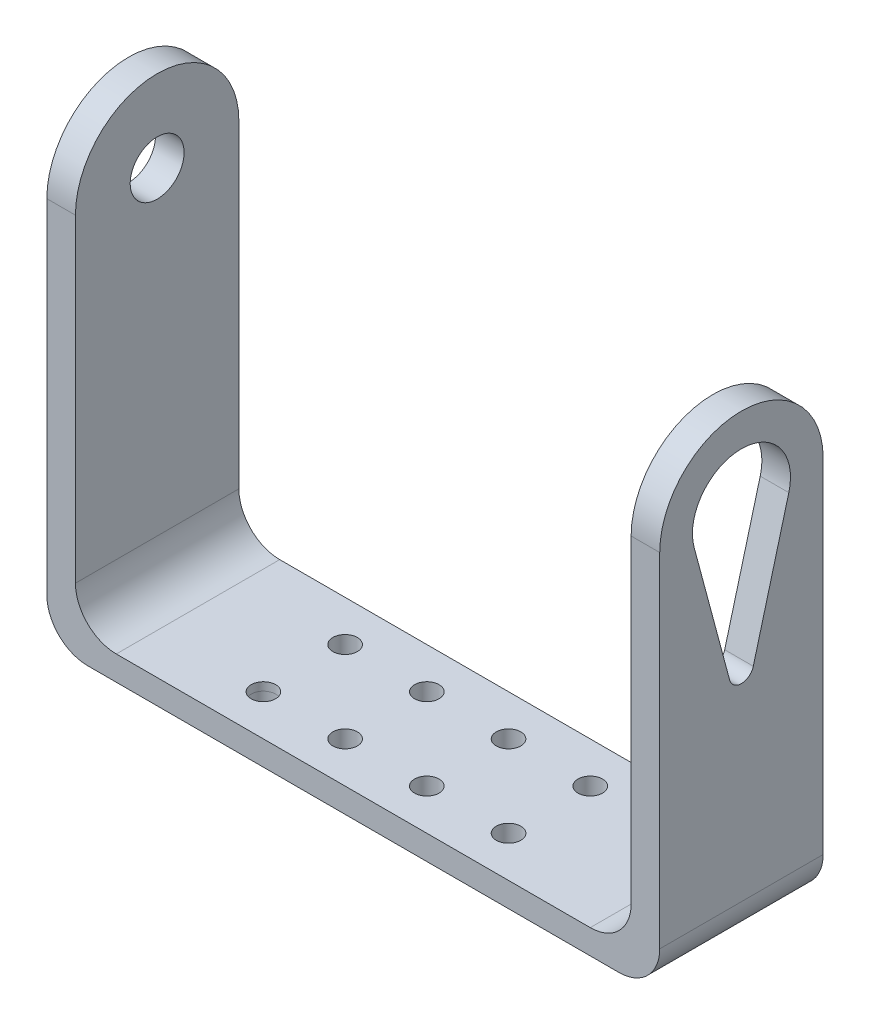
from build123d import *

# Parameters (mm, degrees)
SKETCH_2_R          = 1.5
EXTRUDE_1_DEPTH     = 2
SKETCH_3_W          = 2
SKETCH_3_H          = 20
SKETCH_3_W_2        = 3.5
EXTRUDE_2_DEPTH     = 55
SKETCH_9_R          = 6
CUT_EXTRUDE_1_DEPTH = 87
SKETCH_7_R          = 6
SKETCH_7_R_2        = 3.3
EXTRUDE_3_DEPTH     = 2
SKETCH_10_R         = 3.3
EXTRUDE_4_DEPTH     = 1.5
SKETCH_11_W         = 68
SKETCH_11_H         = 20
SKETCH_11_R         = 1.5
SKETCH_11_R_2       = 1.498871695
EXTRUDE_5_DEPTH     = 1
FILLET_6_R          = 5
FILLET_7_R          = 5
FILLET_8_R          = 5
CUT_EXTRUDE_2_DEPTH = 3.5


with BuildPart() as part:
    # 스케치2 → 보스-돌출1 (new body)
    with BuildSketch(Plane(origin=(0, 0, 0), x_dir=(1, 0, 0), z_dir=(0, 1, 0))):
        Polygon((35, -10), (-35, -10), (-35, 10), (35, 10), (38.5, 10), (38.5, -10), align=None)
        with Locations((-15, 5)):
            Circle(SKETCH_2_R, mode=Mode.SUBTRACT)
        with Locations((-5, 5)):
            Circle(SKETCH_2_R, mode=Mode.SUBTRACT)
        with Locations((-15, -5)):
            Circle(SKETCH_2_R, mode=Mode.SUBTRACT)
        with Locations((-5, -5)):
            Circle(SKETCH_2_R, mode=Mode.SUBTRACT)
        with Locations((15, -5)):
            Circle(SKETCH_2_R, mode=Mode.SUBTRACT)
        with Locations((5, -5)):
            Circle(SKETCH_2_R, mode=Mode.SUBTRACT)
        with Locations((5, 5)):
            Circle(SKETCH_2_R, mode=Mode.SUBTRACT)
        with Locations((15, 5)):
            Circle(SKETCH_2_R, mode=Mode.SUBTRACT)
    extrude(amount=EXTRUDE_1_DEPTH)

    # 스케치3 → 보스-돌출2 (add)
    with BuildSketch(Plane(origin=(0, 2, 0), x_dir=(1, 0, 0), z_dir=(0, 1, 0))):
        with Locations((-34, 0)):
            Rectangle(SKETCH_3_W, SKETCH_3_H)
        with Locations((36.75, 0)):
            Rectangle(SKETCH_3_W_2, SKETCH_3_H)
    extrude(amount=EXTRUDE_2_DEPTH)

    # 스케치9 → 컷-돌출1 (cut)
    with BuildSketch(Plane(origin=(38.5, 0, 0), x_dir=(0, 0, -1), z_dir=(1, 0, 0))):
        with BuildLine():
            Line((10, 57), (0, 57))
            ThreePointArc((0, 57), (7.071067812, 54.071067812), (10, 47))
            Line((10, 47), (10, 57))
        make_face()
        with BuildLine():
            Line((-10, 57), (-10, 47))
            ThreePointArc((-10, 47), (-7.071067812, 54.071067812), (0, 57))
            Line((0, 57), (-10, 57))
        make_face()
        with Locations((0, 47)):
            Circle(SKETCH_9_R)
    extrude(amount=-CUT_EXTRUDE_1_DEPTH, mode=Mode.SUBTRACT)

    # 스케치7 → 보스-돌출3 (add)
    with BuildSketch(Plane.ZY.offset(35)):
        with Locations((0, 47)):
            Circle(SKETCH_7_R)
        with Locations((0, 47)):
            Circle(SKETCH_7_R_2, mode=Mode.SUBTRACT)
    extrude(amount=-EXTRUDE_3_DEPTH)

    # 스케치10 → 보스-돌출4 (add)
    with BuildSketch(Plane.ZY.offset(35)):
        with BuildLine():
            ThreePointArc((-10, 47), (0, 57), (10, 47))
            Line((10, 47), (10, 0))
            Line((10, 0), (-10, 0))
            Line((-10, 0), (-10, 47))
        make_face()
        with Locations((0, 47)):
            Circle(SKETCH_10_R, mode=Mode.SUBTRACT)
    extrude(amount=EXTRUDE_4_DEPTH)

    # 스케치11 → 보스-돌출5 (add)
    with BuildSketch(Plane(origin=(0, 2, 0), x_dir=(1, 0, 0), z_dir=(0, 1, 0))):
        with Locations((1, 0)):
            Rectangle(SKETCH_11_W, SKETCH_11_H)
        with Locations((-15, 5)):
            Circle(SKETCH_11_R, mode=Mode.SUBTRACT)
        with Locations((-5, 5)):
            Circle(SKETCH_11_R, mode=Mode.SUBTRACT)
        with Locations((5, 5)):
            Circle(SKETCH_11_R, mode=Mode.SUBTRACT)
        with Locations((15, 5)):
            Circle(SKETCH_11_R, mode=Mode.SUBTRACT)
        with Locations((15, -5)):
            Circle(SKETCH_11_R, mode=Mode.SUBTRACT)
        with Locations((5, -5)):
            Circle(SKETCH_11_R, mode=Mode.SUBTRACT)
        with Locations((-5, -5)):
            Circle(SKETCH_11_R, mode=Mode.SUBTRACT)
        with Locations((-15, -5)):
            Circle(SKETCH_11_R_2, mode=Mode.SUBTRACT)
    extrude(amount=EXTRUDE_5_DEPTH)

    # 필렛6
    fillet_6_edges = [part.edges().sort_by_distance(p)[0] for p in [
        (-33, 3, 0),
    ]]
    fillet(fillet_6_edges, radius=FILLET_6_R)

    # 필렛7
    fillet_7_edges = [part.edges().sort_by_distance(p)[0] for p in [
        (35, 3, 0),
    ]]
    fillet(fillet_7_edges, radius=FILLET_7_R)

    # 필렛8
    fillet_8_edges = [part.edges().sort_by_distance(p)[0] for p in [
        (-36.5, 0, 0),
        (38.5, 0, 0),
    ]]
    fillet(fillet_8_edges, radius=FILLET_8_R)

    # 스케치12 → 컷-돌출2 (cut)
    with BuildSketch(Plane(origin=(38.5, 0, 0), x_dir=(0, 0, -1), z_dir=(1, 0, 0))):
        with BuildLine():
            ThreePointArc((-1.448888739, 29.225106559), (0, 28.113335127), (1.448888739, 29.225106559))
            Line((1.448888739, 29.225106559), (5.795554958, 45.447085729))
            ThreePointArc((5.795554958, 45.447085729), (0, 41), (-5.795554958, 45.447085729))
            Line((-5.795554958, 45.447085729), (-1.448888739, 29.225106559))
        make_face()
    extrude(amount=-CUT_EXTRUDE_2_DEPTH, mode=Mode.SUBTRACT)


solid = part.part
